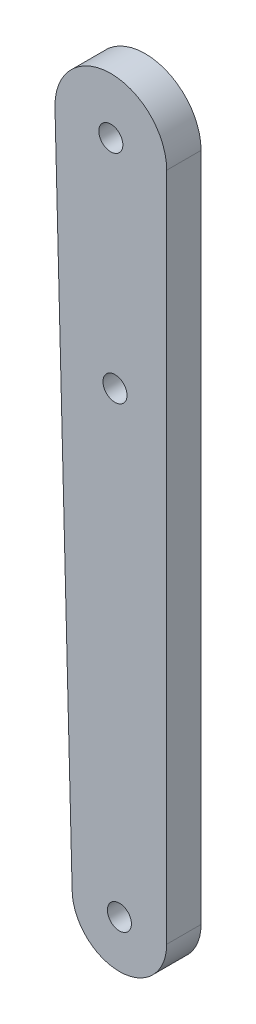
from build123d import *

# Parameters (mm, degrees)
SKETCH1_R           = 1.4
BOSS_EXTRUDE2_DEPTH = 4


with BuildPart() as part:
    # Sketch1 → Boss-Extrude2 (new body)
    with BuildSketch(Plane.XY):
        with BuildLine():
            Line((-0.000688459, -12.983908279), (-0.000688459, 65.016091721))
            ThreePointArc((-0.000688459, 65.016091721), (-6.500688459, 71.516091721), (-13.000688459, 65.016091721))
            Line((-13.000688459, 65.016091721), (-11.000688459, -12.983908279))
            ThreePointArc((-11.000688459, -12.983908279), (-5.500688459, -18.483908279), (-0.000688459, -12.983908279))
        make_face()
        with Locations((-6.500688459, 65.016091721)):
            Circle(SKETCH1_R, mode=Mode.SUBTRACT)
        with Locations((-5.500688459, -12.983908279)):
            Circle(SKETCH1_R, mode=Mode.SUBTRACT)
        with Locations((-6.012756351, 40.016091721)):
            Circle(SKETCH1_R, mode=Mode.SUBTRACT)
    extrude(amount=BOSS_EXTRUDE2_DEPTH)


solid = part.part
